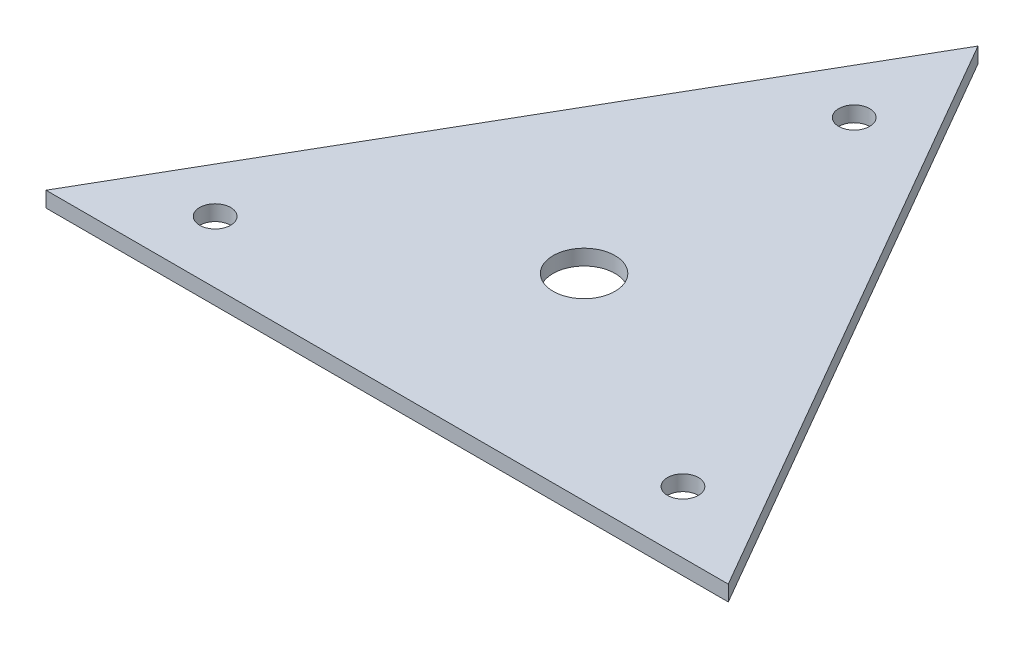
from build123d import *

# Parameters (mm, degrees)
SKETCH1_R           = 6.35
SKETCH1_R_2         = 3.175
BOSS_EXTRUDE1_DEPTH = 3.175


with BuildPart() as part:
    # Sketch1 → Boss-Extrude1 (new body)
    with BuildSketch(Plane(origin=(0, 0, 0), x_dir=(1, 0, 0), z_dir=(0, 1, 0))):
        Polygon((0, 0), (139.954, 0), (69.977, 121.203719361), align=None)
        with Locations((69.977, 40.401239787)):
            Circle(SKETCH1_R, mode=Mode.SUBTRACT)
        with Locations((117.956954744, 12.7)):
            Circle(SKETCH1_R_2, mode=Mode.SUBTRACT)
        with Locations((21.997045256, 12.7)):
            Circle(SKETCH1_R_2, mode=Mode.SUBTRACT)
        with Locations((69.977, 95.803719361)):
            Circle(SKETCH1_R_2, mode=Mode.SUBTRACT)
    extrude(amount=BOSS_EXTRUDE1_DEPTH)


solid = part.part
